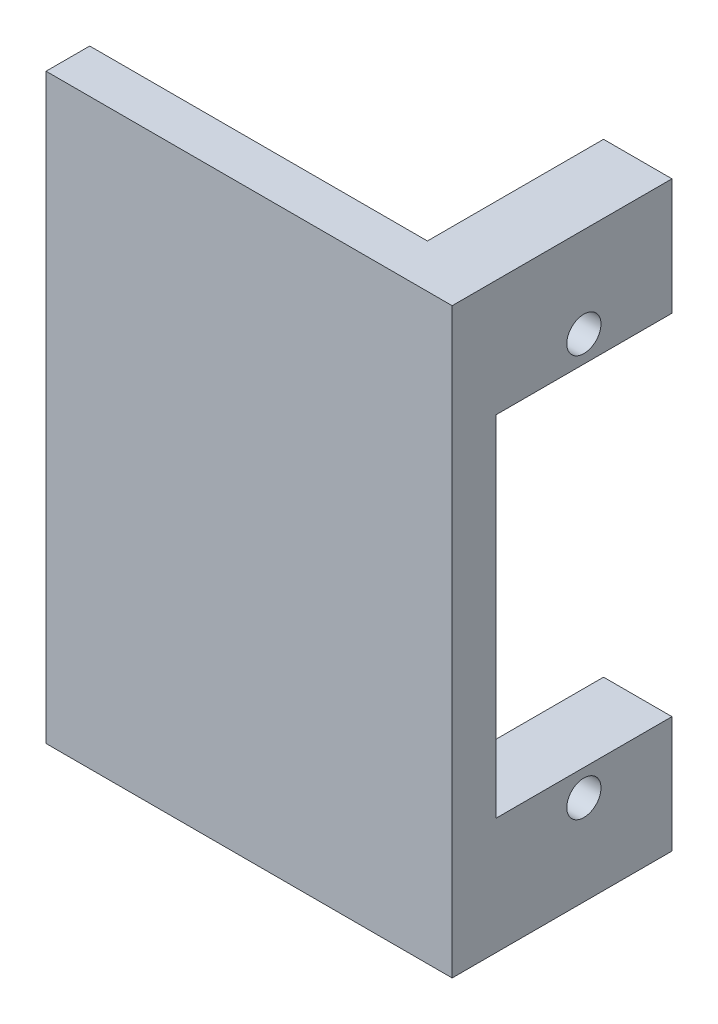
from build123d import *

# Parameters (mm, degrees)
BOSS_EXTRUDE1_DEPTH = 40
SKETCH2_W           = 12.1
SKETCH2_H           = 24
CUT_EXTRUDE3_DEPTH  = 4.7
SKETCH4_R           = 1.175
CUT_EXTRUDE4_DEPTH  = 4.7


with BuildPart() as part:
    # Sketch1 → Boss-Extrude1 (new body)
    with BuildSketch(Plane(origin=(0, 0, 0), x_dir=(1, 0, 0), z_dir=(0, 1, 0))):
        Polygon((0, 12.1), (4.7, 12.1), (4.7, -3), (-23.2, -3), (-23.2, 0), (0, 0), align=None)
    extrude(amount=BOSS_EXTRUDE1_DEPTH)

    # Sketch2 → Cut-Extrude3 (cut)
    with BuildSketch(Plane(origin=(4.7, 0, 0), x_dir=(0, 0, -1), z_dir=(1, 0, 0))):
        with Locations((6.05, 20)):
            Rectangle(SKETCH2_W, SKETCH2_H)
    extrude(amount=-CUT_EXTRUDE3_DEPTH, mode=Mode.SUBTRACT)

    # Sketch4 → Cut-Extrude4 (cut)
    with BuildSketch(Plane(origin=(4.7, 0, 0), x_dir=(0, 0, -1), z_dir=(1, 0, 0))):
        with Locations((6.05, 33.8)):
            Circle(SKETCH4_R)
        with Locations((6.05, 6.2)):
            Circle(SKETCH4_R)
    extrude(amount=-CUT_EXTRUDE4_DEPTH, mode=Mode.SUBTRACT)


solid = part.part
